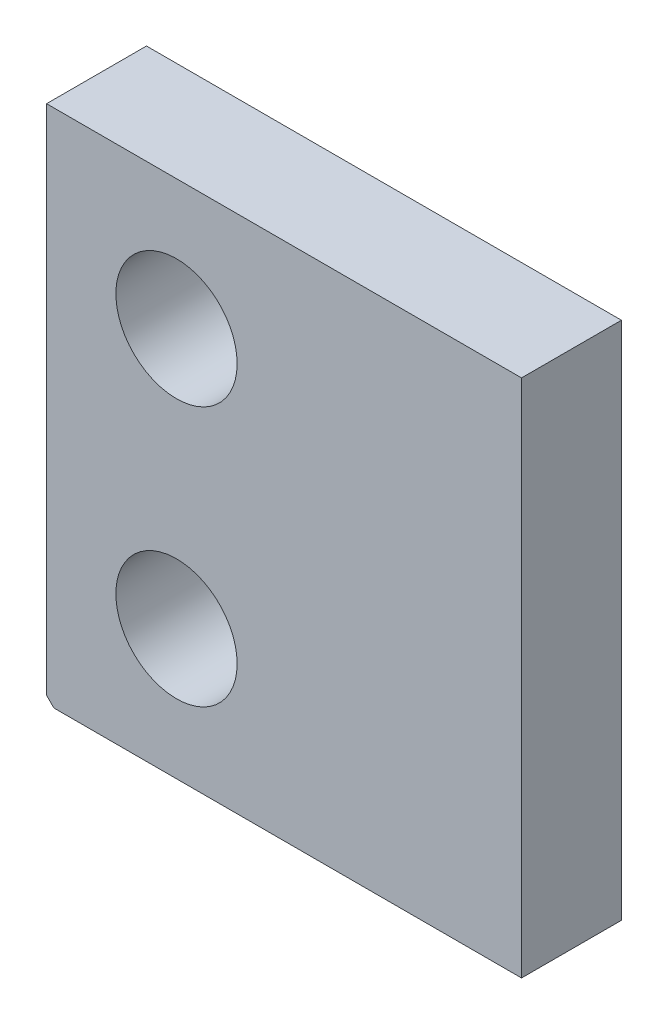
from build123d import *

# Parameters (mm, degrees)
SKETCH1_W            = 32.9
SKETCH1_H            = 36
BOSS_EXTRUDE1_DEPTH  = 6.92
M8_CLEARANCE_HOLE1_D = 8.4
CHAMFER1_SIZE        = 0.508


with BuildPart() as part:
    # Sketch1 → Boss-Extrude1 (new body)
    with BuildSketch(Plane.XY):
        Rectangle(SKETCH1_W, SKETCH1_H)
    extrude(amount=BOSS_EXTRUDE1_DEPTH)

    # M8 Clearance Hole1 (through all)
    with Locations(Plane.XY.offset(6.92)):
        with Locations((-7.449999987, -9), (-7.449999987, 9)):
            Hole(M8_CLEARANCE_HOLE1_D / 2)

    # Chamfer1
    chamfer1_edges = [part.edges().sort_by_distance(p)[0] for p in [
        (-16.45, -18, 3.46),
    ]]
    chamfer(chamfer1_edges, length=CHAMFER1_SIZE)


solid = part.part
